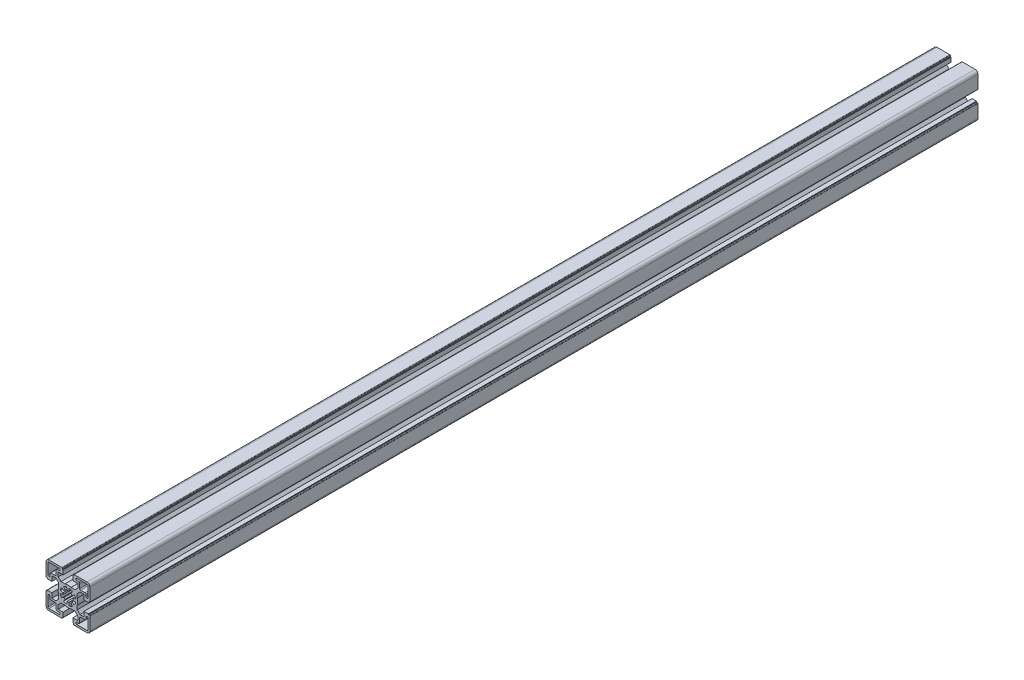
from build123d import *

# Parameters (mm, degrees)
BASE_EXTRUDE_DEPTH = 910


with BuildPart() as part:
    # Sketch1 → Base-Extrude (new body)
    with BuildSketch(Plane.XY):
        with BuildLine():
            Line((-4.99999574, -16.499883971), (-4.99999574, -20.99990968))
            Line((-4.99999574, -20.99990968), (-5.80004044, -20.99990968))
            Line((-5.80004044, -20.99990968), (-5.80004044, -21.999970054))
            ThreePointArc((-5.80004044, -21.999970054), (-5.946487232, -22.353523887), (-6.300041066, -22.49997068))
            Line((-6.300041066, -22.49997068), (-19.500014911, -22.49997068))
            ThreePointArc((-19.500014911, -22.49997068), (-21.62133367, -21.62129168), (-22.50001267, -19.499972921))
            Line((-22.50001267, -19.499972921), (-22.50001267, -6.299929564))
            ThreePointArc((-22.50001267, -6.299929564), (-22.353566213, -5.946376541), (-22.00001319, -5.799930084))
            Line((-22.00001319, -5.799930084), (-21.000012806, -5.799930084))
            Line((-21.000012806, -5.799930084), (-21.000012806, -4.999940084))
            Line((-21.000012806, -4.999940084), (-16.500012806, -4.999940084))
            Line((-16.500012806, -4.999940084), (-16.500012806, -10.049940084))
            Line((-16.500012806, -10.049940084), (-12.342923806, -10.049940084))
            Line((-12.342923806, -10.049940084), (-9.499953806, -7.206970084))
            Line((-9.499953806, -7.206970084), (-9.499953806, -3.122617084))
            ThreePointArc((-9.499953806, -3.122617084), (-10.000013376, 6.1916e-05), (-9.499953806, 3.122740916))
            Line((-9.499953806, 3.122740916), (-9.499953806, 7.206970084))
            Line((-9.499953806, 7.206970084), (-12.342923806, 10.049940084))
            Line((-12.342923806, 10.049940084), (-16.500012806, 10.049940084))
            Line((-16.500012806, 10.049940084), (-16.500012806, 4.999940084))
            Line((-16.500012806, 4.999940084), (-21.000012806, 4.999940084))
            Line((-21.000012806, 4.999940084), (-21.000012806, 5.799930084))
            Line((-21.000012806, 5.799930084), (-22.00001319, 5.799930084))
            ThreePointArc((-22.00001319, 5.799930084), (-22.353566213, 5.946376541), (-22.50001267, 6.299929564))
            Line((-22.50001267, 6.299929564), (-22.50001267, 19.499972921))
            ThreePointArc((-22.50001267, 19.499972921), (-21.62133367, 21.62129168), (-19.500014911, 22.49997068))
            Line((-19.500014911, 22.49997068), (-6.299954884, 22.49997068))
            ThreePointArc((-6.299954884, 22.49997068), (-5.946364566, 22.353508775), (-5.799902661, 21.999918456))
            Line((-5.799902661, 21.999918456), (-5.799902661, 20.999918083))
            Line((-5.799902661, 20.999918083), (-4.99999574, 20.999918083))
            Line((-4.99999574, 20.999918083), (-4.99999574, 16.499989166))
            Line((-4.99999574, 16.499989166), (-10.050086009, 16.499989166))
            Line((-10.050086009, 16.499989166), (-10.050086009, 12.342794971))
            Line((-10.050086009, 12.342794971), (-7.207151696, 9.499860659))
            Line((-7.207151696, 9.499860659), (-3.122798696, 9.499860659))
            ThreePointArc((-3.122798696, 9.499860659), (-0.000120196, 9.999920064), (3.122558304, 9.499860659))
            Line((3.122558304, 9.499860659), (7.206958901, 9.499860659))
            Line((7.206958901, 9.499860659), (10.049884116, 12.342787874))
            Line((10.049884116, 12.342787874), (10.049884116, 16.499989166))
            Line((10.049884116, 16.499989166), (4.99999574, 16.499989166))
            Line((4.99999574, 16.499989166), (4.99999574, 20.999963909))
            Line((4.99999574, 20.999963909), (5.799902661, 20.999963909))
            Line((5.799902661, 20.999963909), (5.799902661, 21.999918456))
            ThreePointArc((5.799902661, 21.999918456), (5.946364566, 22.353508775), (6.299954884, 22.49997068))
            Line((6.299954884, 22.49997068), (19.500081571, 22.49997068))
            ThreePointArc((19.500081571, 22.49997068), (21.62140033, 21.62129168), (22.50007933, 19.499972921))
            Line((22.50007933, 19.499972921), (22.50007933, 6.299877709))
            ThreePointArc((22.50007933, 6.299877709), (22.35363283, 5.946324583), (22.000079704, 5.799878083))
            Line((22.000079704, 5.799878083), (20.999995421, 5.799878083))
            Line((20.999995421, 5.799878083), (20.999995421, 4.999941084))
            Line((20.999995421, 4.999941084), (16.499983596, 4.999941084))
            Line((16.499983596, 4.999941084), (16.499983596, 10.049940084))
            Line((16.499983596, 10.049940084), (12.342894596, 10.049940084))
            Line((12.342894596, 10.049940084), (9.499922596, 7.206970084))
            Line((9.499922596, 7.206970084), (9.499922596, 3.122735916))
            ThreePointArc((9.499922596, 3.122735916), (9.999982165, 5.6916e-05), (9.499922596, -3.122622084))
            Line((9.499922596, -3.122622084), (9.499922596, -7.206970084))
            Line((9.499922596, -7.206970084), (12.342894596, -10.049940084))
            Line((12.342894596, -10.049940084), (16.499983596, -10.049940084))
            Line((16.499983596, -10.049940084), (16.499983596, -4.999941084))
            Line((16.499983596, -4.999941084), (20.999995421, -4.999941084))
            Line((20.999995421, -4.999941084), (20.999995421, -5.799878083))
            Line((20.999995421, -5.799878083), (22.000079704, -5.799878083))
            ThreePointArc((22.000079704, -5.799878083), (22.35363283, -5.946324583), (22.50007933, -6.299877709))
            Line((22.50007933, -6.299877709), (22.50007933, -19.499973421))
            ThreePointArc((22.50007933, -19.499973421), (21.621400476, -21.621291826), (19.500082071, -22.49997068))
            Line((19.500082071, -22.49997068), (6.300041066, -22.49997068))
            ThreePointArc((6.300041066, -22.49997068), (5.946487232, -22.353523887), (5.80004044, -21.999970054))
            Line((5.80004044, -21.999970054), (5.80004044, -20.99990968))
            Line((5.80004044, -20.99990968), (4.99999574, -20.99990968))
            Line((4.99999574, -20.99990968), (4.99999574, -16.499883971))
            Line((4.99999574, -16.499883971), (10.049884116, -16.499883971))
            Line((10.049884116, -16.499883971), (10.049884116, -12.342787874))
            Line((10.049884116, -12.342787874), (7.206933602, -9.49983536))
            Line((7.206933602, -9.49983536), (3.122579602, -9.49983536))
            ThreePointArc((3.122579602, -9.49983536), (-9.9398e-05, -9.99989493), (-3.122778398, -9.49983536))
            Line((-3.122778398, -9.49983536), (-7.207126398, -9.49983536))
            Line((-7.207126398, -9.49983536), (-10.050086009, -12.342794971))
            Line((-10.050086009, -12.342794971), (-10.050086009, -16.499883971))
            Line((-10.050086009, -16.499883971), (-4.99999574, -16.499883971))
        make_face()
        with BuildLine():
            Line((0.868239441, 4.924019626), (1.389186106, 7.878448412))
            ThreePointArc((1.389186106, 7.878448412), (3.061471579, 7.391020172), (4.588617704, 6.553195784))
            Line((4.588617704, 6.553195784), (2.867879873, 4.095738521))
            ThreePointArc((2.867879873, 4.095738521), (3.535523556, 3.535517244), (4.095743641, 2.867872561))
            Line((4.095743641, 2.867872561), (6.553203976, 4.588606005))
            ThreePointArc((6.553203976, 4.588606005), (7.391023332, 3.061463952), (7.878448799, 1.389183909))
            Line((7.878448799, 1.389183909), (4.924019868, 0.868238068))
            ThreePointArc((4.924019868, 0.868238068), (4.9999809, 7.81e-07), (4.924020139, -0.868236529))
            Line((4.924020139, -0.868236529), (7.878449234, -1.389181447))
            ThreePointArc((7.878449234, -1.389181447), (7.391025132, -3.061459606), (6.553207937, -4.588600349))
            Line((6.553207937, -4.588600349), (4.095746117, -2.867869026))
            ThreePointArc((4.095746117, -2.867869026), (3.535522832, -3.535517968), (2.86787466, -4.095742171))
            Line((2.86787466, -4.095742171), (4.588609364, -6.553201624))
            ThreePointArc((4.588609364, -6.553201624), (3.061466598, -7.391022236), (1.389185513, -7.878448517))
            Line((1.389185513, -7.878448517), (0.868239071, -4.924019691))
            ThreePointArc((0.868239071, -4.924019691), (8.15e-07, -4.9999809), (-0.868237465, -4.924019974))
            Line((-0.868237465, -4.924019974), (-1.389182943, -7.87844897))
            ThreePointArc((-1.389182943, -7.87844897), (-3.06146423, -7.391023216), (-4.588607303, -6.553203067))
            Line((-4.588607303, -6.553203067), (-2.867873372, -4.095743073))
            ThreePointArc((-2.867873372, -4.095743073), (-3.535520061, -3.535520739), (-4.095742523, -2.867874158))
            Line((-4.095742523, -2.867874158), (-6.553202186, -4.588608561))
            ThreePointArc((-6.553202186, -4.588608561), (-7.391024272, -3.061461681), (-7.878450195, -1.389175997))
            Line((-7.878450195, -1.389175997), (-4.92402074, -0.868233124))
            ThreePointArc((-4.92402074, -0.868233124), (-4.9999809, 1.729e-06), (-4.924020139, 0.868236529))
            Line((-4.924020139, 0.868236529), (-7.878449234, 1.389181447))
            ThreePointArc((-7.878449234, 1.389181447), (-7.391023494, 3.061463561), (-6.553203027, 4.588607361))
            Line((-6.553203027, 4.588607361), (-4.095743048, 2.867873408))
            ThreePointArc((-4.095743048, 2.867873408), (-3.535525782, 3.535515019), (-2.867885877, 4.095734317))
            Line((-2.867885877, 4.095734317), (-4.588627311, 6.553189058))
            ThreePointArc((-4.588627311, 6.553189058), (-3.061465289, 7.391022778), (-1.389161147, 7.878452813))
            Line((-1.389161147, 7.878452813), (-0.868223842, 4.924022376))
            ThreePointArc((-0.868223842, 4.924022376), (7.92e-06, 4.9999809), (0.868239441, 4.924019626))
        make_face(mode=Mode.SUBTRACT)
        with BuildLine():
            Line((-17.500118733, -12.000017917), (-13.000117238, -12.000017917))
            ThreePointArc((-13.000117238, -12.000017917), (-12.293010985, -12.292910917), (-12.000117985, -13.00001717))
            Line((-12.000117985, -13.00001717), (-12.000117985, -17.49992083))
            ThreePointArc((-12.000117985, -17.49992083), (-11.707224985, -18.207027083), (-11.000118733, -18.499920083))
            Line((-11.000118733, -18.499920083), (-9.000117985, -18.499920083))
            ThreePointArc((-9.000117985, -18.499920083), (-8.000069068, -19.499969), (-9.000117985, -20.500017917))
            Line((-9.000117985, -20.500017917), (-19.500118733, -20.500017917))
            ThreePointArc((-19.500118733, -20.500017917), (-20.207224985, -20.207124917), (-20.500117985, -19.500018664))
            Line((-20.500117985, -19.500018664), (-20.500117985, -8.999920083))
            ThreePointArc((-20.500117985, -8.999920083), (-19.500117985, -7.999920083), (-18.500117985, -8.999920083))
            Line((-18.500117985, -8.999920083), (-18.500117985, -11.000018664))
            ThreePointArc((-18.500117985, -11.000018664), (-18.207224985, -11.707124917), (-17.500118733, -12.000017917))
        make_face(mode=Mode.SUBTRACT)
        with BuildLine():
            Line((13.000003267, -12.000017917), (17.500004762, -12.000017917))
            ThreePointArc((17.500004762, -12.000017917), (18.207111015, -11.707124917), (18.500004015, -11.000018664))
            Line((18.500004015, -11.000018664), (18.500004015, -9.000115751))
            ThreePointArc((18.500004015, -9.000115751), (19.500004015, -8.000115751), (20.500004015, -9.000115751))
            Line((20.500004015, -9.000115751), (20.500004015, -19.500018664))
            ThreePointArc((20.500004015, -19.500018664), (20.207111015, -20.207124917), (19.500004762, -20.500017917))
            Line((19.500004762, -20.500017917), (9.000004015, -20.500017917))
            ThreePointArc((9.000004015, -20.500017917), (7.999955097, -19.499969), (9.000004015, -18.499920083))
            Line((9.000004015, -18.499920083), (11.000004762, -18.499920083))
            ThreePointArc((11.000004762, -18.499920083), (11.707111015, -18.207027083), (12.000004015, -17.49992083))
            Line((12.000004015, -17.49992083), (12.000004015, -13.00001717))
            ThreePointArc((12.000004015, -13.00001717), (12.292897015, -12.292910917), (13.000003267, -12.000017917))
        make_face(mode=Mode.SUBTRACT)
        with BuildLine():
            Line((-17.500118733, 12.000017917), (-13.000117238, 12.000017917))
            ThreePointArc((-13.000117238, 12.000017917), (-12.293010985, 12.292910917), (-12.000117985, 13.00001717))
            Line((-12.000117985, 13.00001717), (-12.000117985, 17.49992083))
            ThreePointArc((-12.000117985, 17.49992083), (-11.707224985, 18.207027083), (-11.000118733, 18.499920083))
            Line((-11.000118733, 18.499920083), (-9.000117985, 18.499920083))
            ThreePointArc((-9.000117985, 18.499920083), (-8.000069068, 19.499969), (-9.000117985, 20.500017917))
            Line((-9.000117985, 20.500017917), (-19.500118733, 20.500017917))
            ThreePointArc((-19.500118733, 20.500017917), (-20.207224985, 20.207124917), (-20.500117985, 19.500018664))
            Line((-20.500117985, 19.500018664), (-20.500117985, 8.999920083))
            ThreePointArc((-20.500117985, 8.999920083), (-19.500117985, 7.999920083), (-18.500117985, 8.999920083))
            Line((-18.500117985, 8.999920083), (-18.500117985, 11.000018664))
            ThreePointArc((-18.500117985, 11.000018664), (-18.207224985, 11.707124917), (-17.500118733, 12.000017917))
        make_face(mode=Mode.SUBTRACT)
        with BuildLine():
            Line((13.000003267, 12.000017917), (17.500004762, 12.000017917))
            ThreePointArc((17.500004762, 12.000017917), (18.207111015, 11.707124917), (18.500004015, 11.000018664))
            Line((18.500004015, 11.000018664), (18.500004015, 9.000115751))
            ThreePointArc((18.500004015, 9.000115751), (19.500004015, 8.000115751), (20.500004015, 9.000115751))
            Line((20.500004015, 9.000115751), (20.500004015, 19.500018664))
            ThreePointArc((20.500004015, 19.500018664), (20.207111015, 20.207124917), (19.500004762, 20.500017917))
            Line((19.500004762, 20.500017917), (9.000004015, 20.500017917))
            ThreePointArc((9.000004015, 20.500017917), (7.999955097, 19.499969), (9.000004015, 18.499920083))
            Line((9.000004015, 18.499920083), (11.000004762, 18.499920083))
            ThreePointArc((11.000004762, 18.499920083), (11.707111015, 18.207027083), (12.000004015, 17.49992083))
            Line((12.000004015, 17.49992083), (12.000004015, 13.00001717))
            ThreePointArc((12.000004015, 13.00001717), (12.292897015, 12.292910917), (13.000003267, 12.000017917))
        make_face(mode=Mode.SUBTRACT)
    extrude(amount=BASE_EXTRUDE_DEPTH)


solid = part.part
